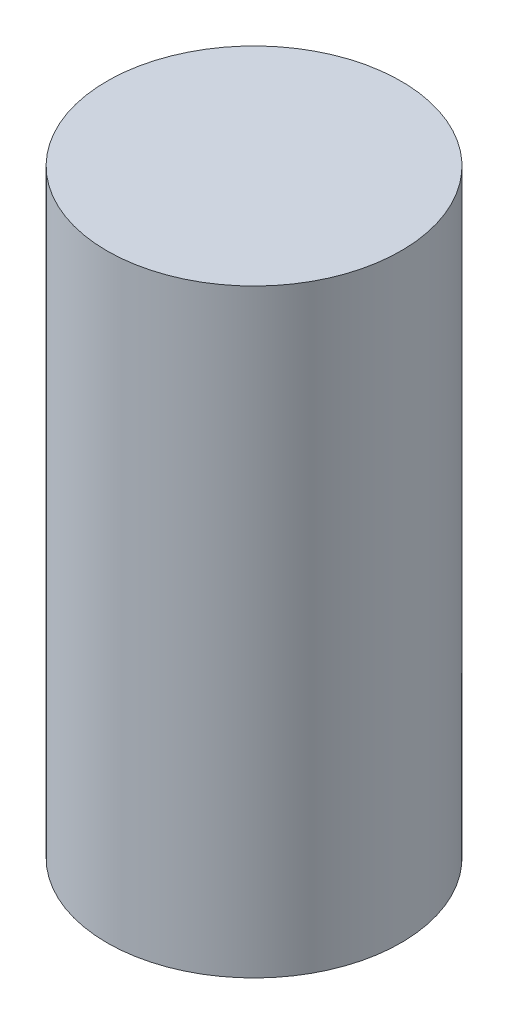
from build123d import *

# Parameters (mm, degrees)
SKETCH1_R           = 7.73
BOSS_EXTRUDE1_DEPTH = 31.5


with BuildPart() as part:
    # Sketch1 → Boss-Extrude1 (new body)
    with BuildSketch(Plane(origin=(0, 0, 0), x_dir=(1, 0, 0), z_dir=(0, 1, 0))):
        Circle(SKETCH1_R)
    extrude(amount=BOSS_EXTRUDE1_DEPTH)


solid = part.part
